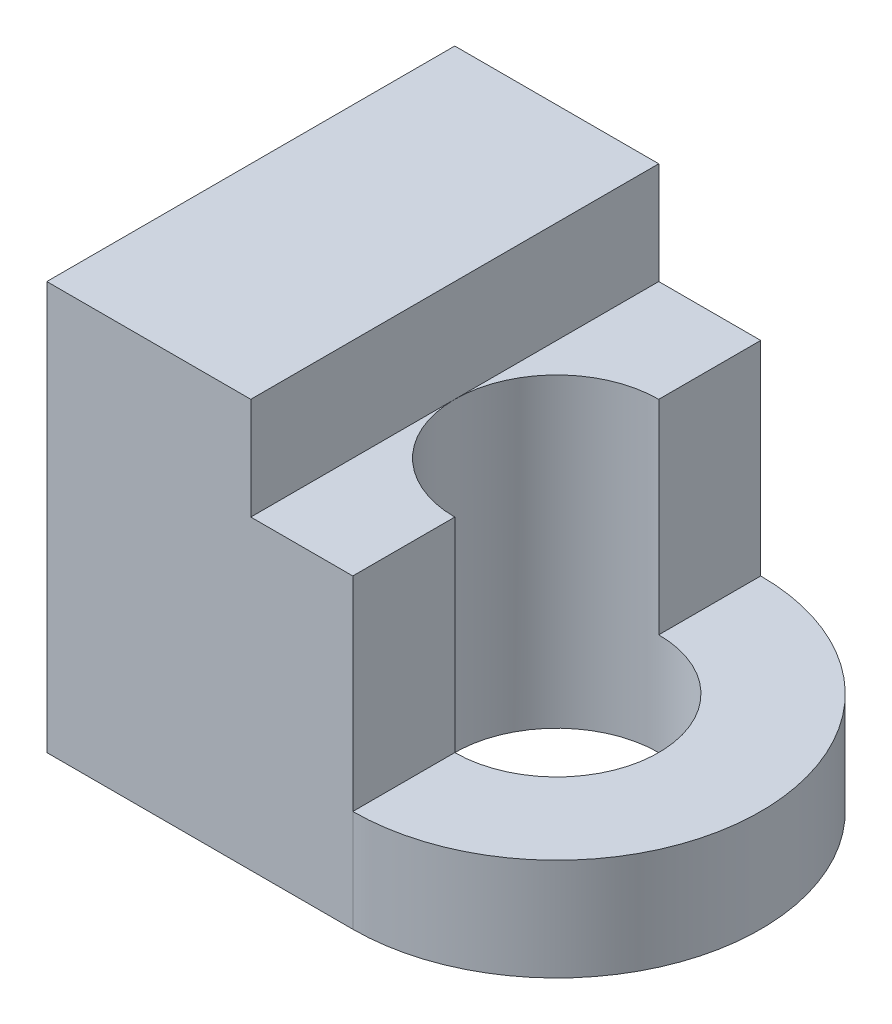
from build123d import *
from build123d.topology import SkipClean

# Parameters (mm, degrees)
SKETCH_1_R      = 5.000000000000002
EXTRUDE_2_DEPTH = 5
EXTRUDE_4_DEPTH = 15
EXTRUDE_5_DEPTH = 20


with BuildPart() as part:
    # 草圖1 → 填料-伸長2 (new body)
    with BuildSketch(Plane(origin=(0, 0, 0), x_dir=(1, 0, 0), z_dir=(0, 1, 0))):
        with BuildLine():
            Line((-15, -10.000000000000002), (0, -10))
            ThreePointArc((0, -10), (10, 2.8e-16), (1.22e-15, 10))
            Line((4.1e-16, 10), (-15, 10))
            Line((-15, 9.999999999999998), (-15, -10.000000000000002))
        make_face()
        Circle(SKETCH_1_R, mode=Mode.SUBTRACT)
    extrude(amount=EXTRUDE_2_DEPTH)

    # 草圖1<4> → 填料-伸長4 (add)
    with BuildSketch(Plane(origin=(0, 0, 0), x_dir=(1, 0, 0), z_dir=(0, 1, 0))):
        with BuildLine():
            Line((-15, -10.000000000000002), (0, -10))
            Line((0, -10), (0, -5))
            ThreePointArc((0, -5), (-5, -3.1e-16), (-6.1e-16, 5))
            Line((0, 5), (0, 10))
            Line((4.1e-16, 10), (-15, 10))
            Line((-15, 9.999999999999998), (-15, -10.000000000000002))
        make_face()
    extrude(amount=EXTRUDE_4_DEPTH)

    # 草圖1<5> → 填料-伸長5 (add)
    with SkipClean():  # the faces are left unmerged after this step: merging them gives an invalid solid
        with BuildSketch(Plane(origin=(0, 0, 0), x_dir=(1, 0, 0), z_dir=(0, 1, 0))):
            Polygon((-15, -10.000000000000002), (-5, -10), (-5, -3.55e-15), (-5, 10), (-15, 10), align=None)
        extrude(amount=EXTRUDE_5_DEPTH)


solid = part.part
